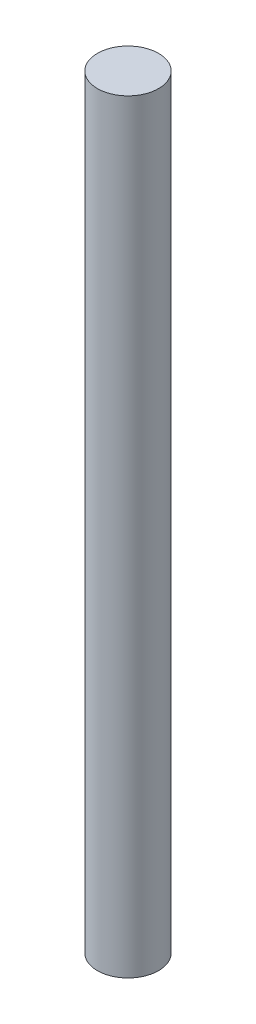
from build123d import *

# Parameters (mm, degrees)
SKETCH1_R           = 2
BOSS_EXTRUDE1_DEPTH = 50


with BuildPart() as part:
    # Sketch1 → Boss-Extrude1 (new body)
    with BuildSketch(Plane(origin=(0, 0, 0), x_dir=(1, 0, 0), z_dir=(0, 1, 0))):
        Circle(SKETCH1_R)
    extrude(amount=BOSS_EXTRUDE1_DEPTH)


solid = part.part
